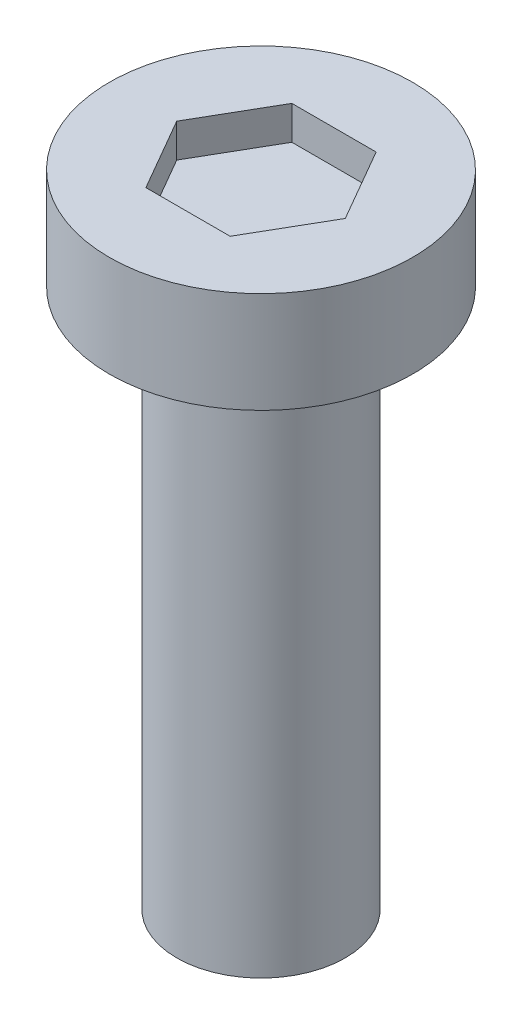
from build123d import *

# Parameters (mm, degrees)
SKETCH1_R           = 1.25
BOSS_EXTRUDE1_DEPTH = 8
SKETCH4_R           = 2.25
BOSS_EXTRUDE2_DEPTH = 1.5
CUT_EXTRUDE1_DEPTH  = 0.5


with BuildPart() as part:
    # Sketch1 → Boss-Extrude1 (new body)
    with BuildSketch(Plane(origin=(0, 0, 0), x_dir=(1, 0, 0), z_dir=(0, 1, 0))):
        Circle(SKETCH1_R)
    extrude(amount=BOSS_EXTRUDE1_DEPTH)

    # Sketch4 → Boss-Extrude2 (add)
    with BuildSketch(Plane(origin=(0, 8, 0), x_dir=(1, 0, 0), z_dir=(0, 1, 0))):
        Circle(SKETCH4_R)
    extrude(amount=BOSS_EXTRUDE2_DEPTH)

    # Sketch5 → Cut-Extrude1 (cut)
    with BuildSketch(Plane(origin=(0, 9.5, 0), x_dir=(1, 0, 0), z_dir=(0, 1, 0))):
        Polygon((1.25, 0), (0.625, 1.082531755), (-0.625, 1.082531755), (-1.25, 0), (-0.625, -1.082531755), (0.625, -1.082531755), align=None)
    extrude(amount=-CUT_EXTRUDE1_DEPTH, mode=Mode.SUBTRACT)


solid = part.part
